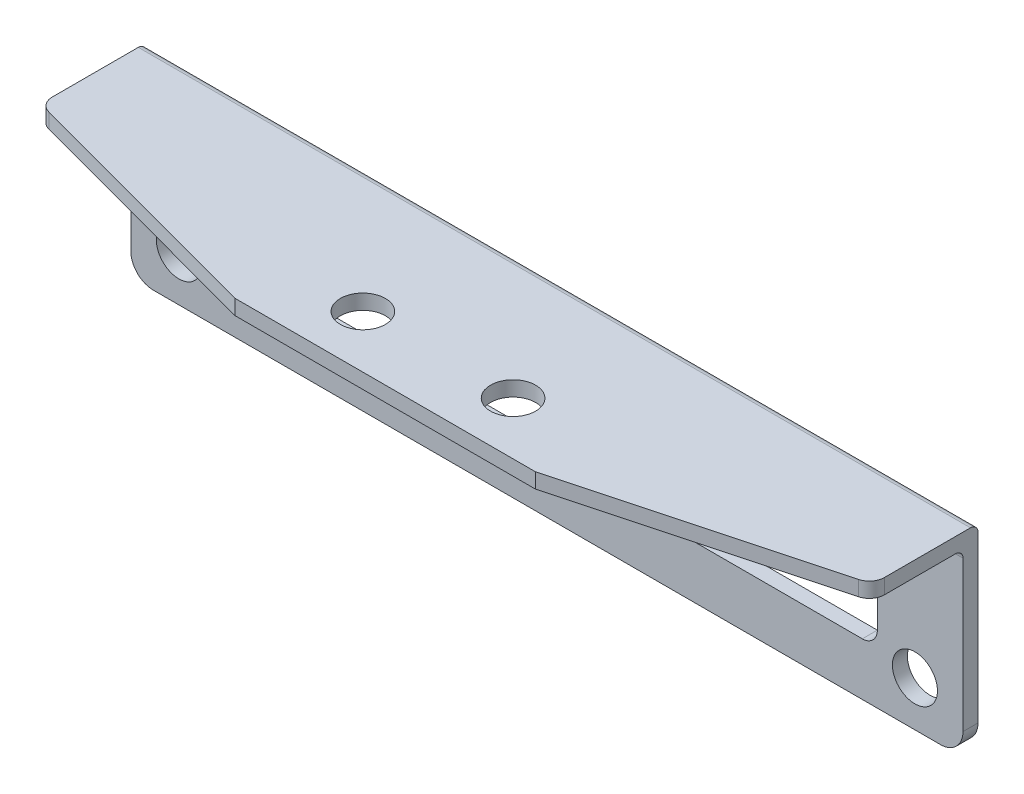
from build123d import *

# Parameters (mm, degrees)
SKETCH_1_W          = 55.4
SKETCH_1_H          = 13
SKETCH_1_R          = 1.5
SKETCH_1_W_2        = 44
SKETCH_1_H_2        = 4.8
EXTRUDE_1_DEPTH     = 1
SKETCH_2_W          = 55.4
SKETCH_2_H          = 1
EXTRUDE_2_DEPTH     = 10.75
CUT_EXTRUDE_1_DEPTH = 2
SKETCH_4_R          = 1.5
CUT_EXTRUDE_2_DEPTH = 2
FILLET_1_R          = 0.5
FILLET_2_R          = 1
FILLET_3_R          = 1.5
FILLET_4_R          = 1


with BuildPart() as part:
    # 草图1 → 凸台-拉伸1 (new body)
    with BuildSketch(Plane.XY):
        with Locations((0, 6.5)):
            Rectangle(SKETCH_1_W, SKETCH_1_H)
        with Locations((-24.5, 3)):
            Circle(SKETCH_1_R, mode=Mode.SUBTRACT)
        with Locations((24.5, 3)):
            Circle(SKETCH_1_R, mode=Mode.SUBTRACT)
        with Locations((0, 5.9)):
            Rectangle(SKETCH_1_W_2, SKETCH_1_H_2, mode=Mode.SUBTRACT)
    extrude(amount=EXTRUDE_1_DEPTH)

    # 草图2 → 凸台-拉伸2 (add)
    with BuildSketch(Plane.XY.offset(1)):
        with Locations((0, 12.5)):
            Rectangle(SKETCH_2_W, SKETCH_2_H)
    extrude(amount=EXTRUDE_2_DEPTH)

    # 草图3 → 切除-拉伸1 (cut, through all)
    with BuildSketch(Plane.XZ.offset(-12)):
        Polygon((-27.7, 11.75), (-27.7, 7), (-10, 11.75), align=None)
        Polygon((27.7, 11.75), (27.7, 7), (10, 11.75), align=None)
    extrude(amount=-CUT_EXTRUDE_1_DEPTH, mode=Mode.SUBTRACT)

    # 草图4 → 切除-拉伸2 (cut, through all)
    with BuildSketch(Plane.XZ.offset(-12)):
        with Locations((-5, 8.25)):
            Circle(SKETCH_4_R)
        with Locations((5, 8.25)):
            Circle(SKETCH_4_R)
    extrude(amount=-CUT_EXTRUDE_2_DEPTH, mode=Mode.SUBTRACT)

    # 圆角1
    fillet_1_edges = [part.edges().sort_by_distance(p)[0] for p in [
        (0, 13, 0),
        (0, 12, 1),
    ]]
    fillet(fillet_1_edges, radius=FILLET_1_R)

    # 圆角2
    fillet_2_edges = [part.edges().sort_by_distance(p)[0] for p in [
        (22, 3.5, 0.5),
        (22, 8.3, 0.5),
        (-22, 8.3, 0.5),
        (-22, 3.5, 0.5),
    ]]
    fillet(fillet_2_edges, radius=FILLET_2_R)

    # 圆角3
    fillet_3_edges = [part.edges().sort_by_distance(p)[0] for p in [
        (27.7, 0, 0.5),
        (-27.7, 0, 0.5),
    ]]
    fillet(fillet_3_edges, radius=FILLET_3_R)

    # 圆角4
    fillet_4_edges = [part.edges().sort_by_distance(p)[0] for p in [
        (-27.7, 12.5, 7),
        (27.7, 12.5, 7),
    ]]
    fillet(fillet_4_edges, radius=FILLET_4_R)


solid = part.part
